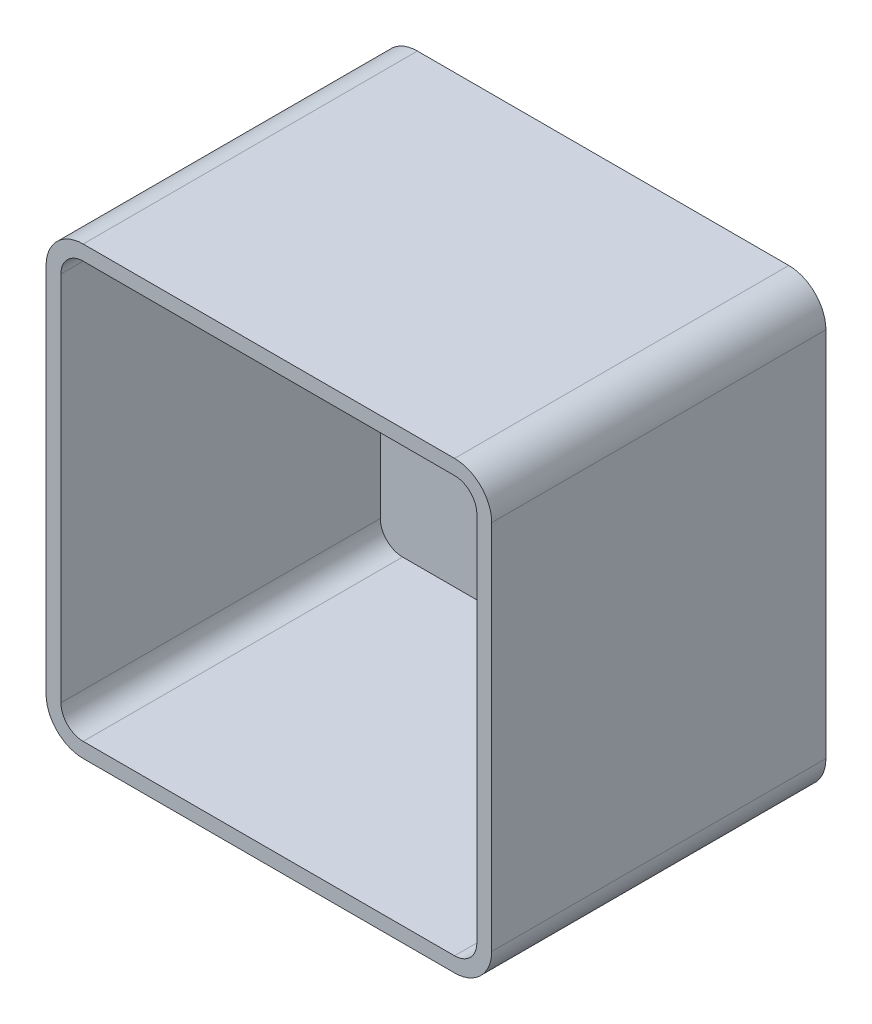
from build123d import *

# Parameters (mm, degrees)
SKETCH2_W           = 120
SKETCH2_H           = 120
BOSS_EXTRUDE1_DEPTH = 90
FILLET1_R           = 10
SHELL2_T            = -4


with BuildPart() as part:
    # Sketch2 → Boss-Extrude1 (new body)
    with BuildSketch(Plane.XY):
        with Locations((60, 60)):
            Rectangle(SKETCH2_W, SKETCH2_H)
    extrude(amount=BOSS_EXTRUDE1_DEPTH)

    # Fillet1
    fillet1_edges = [part.edges().sort_by_distance(p)[0] for p in [
        (0, 120, 45),
        (120, 120, 45),
        (120, 0, 45),
        (0, 0, 45),
    ]]
    fillet(fillet1_edges, radius=FILLET1_R)

    # Shell2
    shell2_openings = [part.faces().sort_by_distance(p)[0] for p in [
        (60, 60, 90),
    ]]
    offset(amount=SHELL2_T, openings=shell2_openings, kind=Kind.INTERSECTION)


solid = part.part
